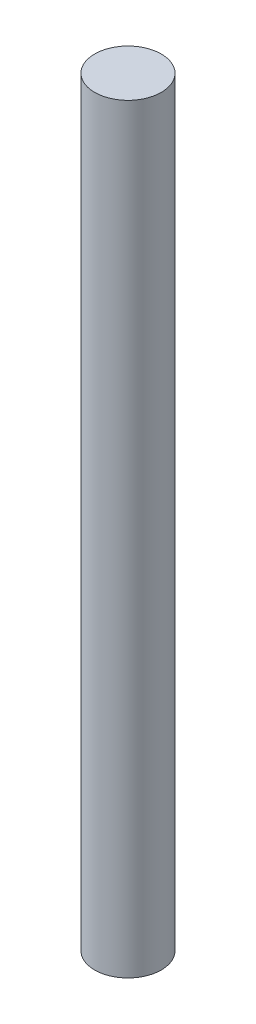
from build123d import *

# Parameters (mm, degrees)
SKETCH1_R           = 12.7
BOSS_EXTRUDE1_DEPTH = 290


with BuildPart() as part:
    # Sketch1 → Boss-Extrude1 (new body)
    with BuildSketch(Plane(origin=(0, 0, 0), x_dir=(1, 0, 0), z_dir=(0, 1, 0))):
        Circle(SKETCH1_R)
    extrude(amount=BOSS_EXTRUDE1_DEPTH)


solid = part.part
